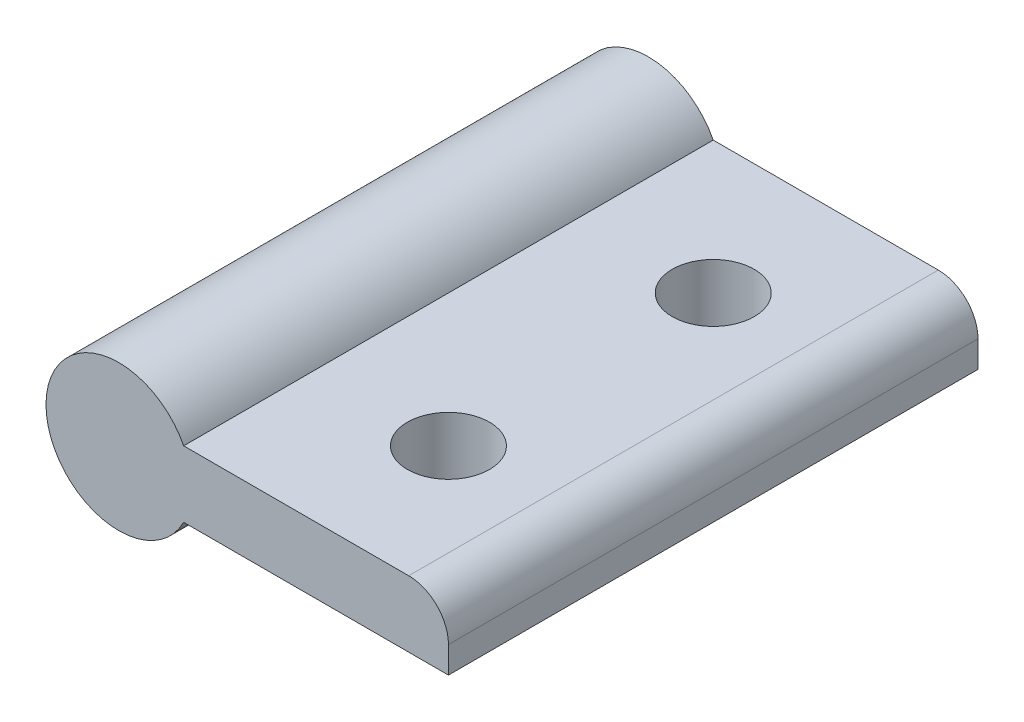
from build123d import *

# Parameters (mm, degrees)
SKETCH1_R           = 5.5
SKETCH1_W           = 20
SKETCH1_H           = 5
BOSS_EXTRUDE1_DEPTH = 40
SKETCH2_R           = 3.1
CUT_EXTRUDE1_DEPTH  = 10
FILLET1_R           = 3


with BuildPart() as part:
    # Sketch1 → Boss-Extrude1 (new body)
    with BuildSketch(Plane.XY):
        Circle(SKETCH1_R)
        with Locations((14.898979486, 0)):
            Rectangle(SKETCH1_W, SKETCH1_H)
    extrude(amount=BOSS_EXTRUDE1_DEPTH)

    # Sketch2 → Cut-Extrude1 (cut)
    with BuildSketch(Plane(origin=(0, 2.5, 0), x_dir=(1, 0, 0), z_dir=(0, 1, 0))):
        with Locations(Location((14.898979486, -10, 0), (0, 0, 270))):  # turned: the seam where the file's is
            Circle(SKETCH2_R)
        with Locations(Location((14.898979486, -30, 0), (0, 0, 270))):  # turned: the seam where the file's is
            Circle(SKETCH2_R)
    extrude(amount=-CUT_EXTRUDE1_DEPTH, mode=Mode.SUBTRACT)

    # Fillet1
    fillet1_edges = [part.edges().sort_by_distance(p)[0] for p in [
        (24.898979486, 2.5, 20),
    ]]
    fillet(fillet1_edges, radius=FILLET1_R)


solid = part.part
